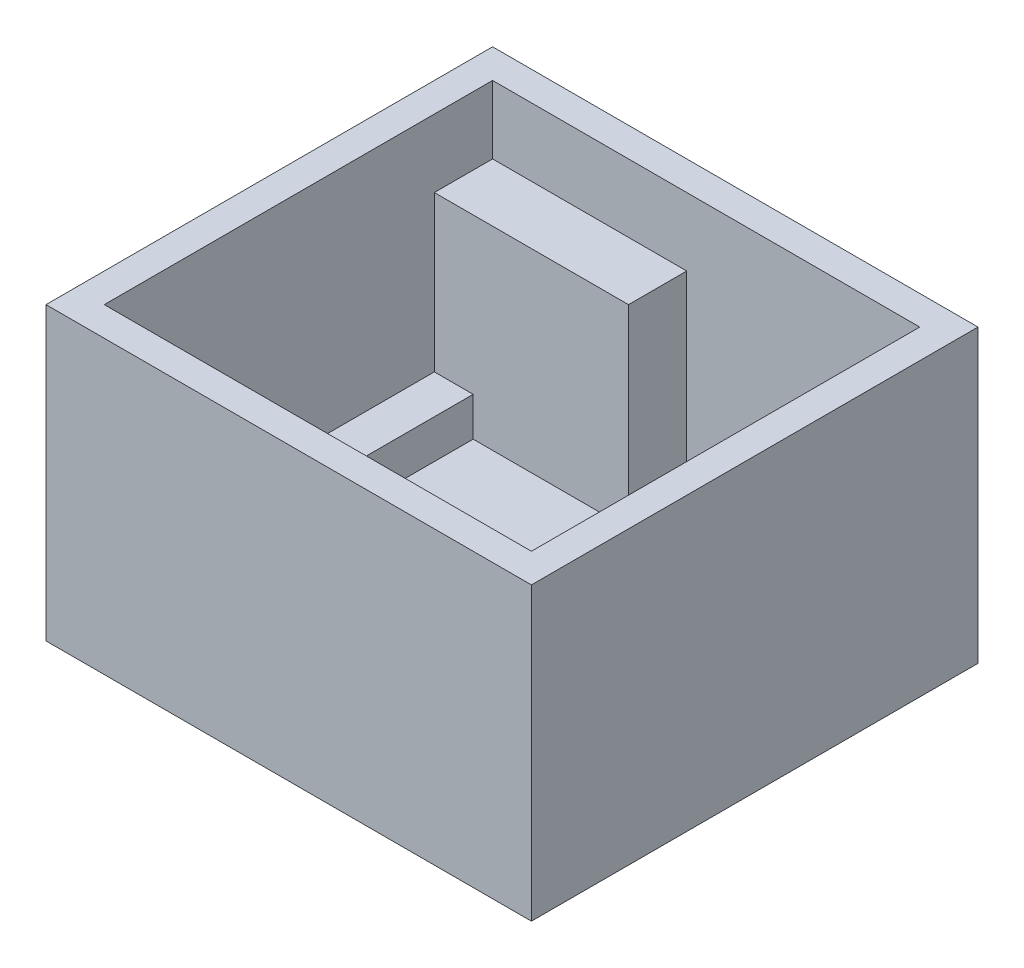
from build123d import *

# Parameters (mm, degrees)
SKETCH1_W           = 25
SKETCH1_H           = 23
BOSS_EXTRUDE1_DEPTH = 15
SHELL1_T            = -1.5
SKETCH3_W           = 2
SKETCH3_H           = 2
BOSS_EXTRUDE2_DEPTH = 2
SKETCH4_W           = 2
SKETCH4_H           = 7
BOSS_EXTRUDE3_DEPTH = 2
SKETCH5_W           = 10
SKETCH5_H           = 3
BOSS_EXTRUDE4_DEPTH = 10
SKETCH2_R           = 1.75
BOSS_EXTRUDE5_DEPTH = 2
SKETCH6_R           = 1.25
BOSS_EXTRUDE6_DEPTH = 4


with BuildPart() as part:
    # Sketch1 → Boss-Extrude1 (new body)
    with BuildSketch(Plane(origin=(0, 0, 0), x_dir=(1, 0, 0), z_dir=(0, 1, 0))):
        Rectangle(SKETCH1_W, SKETCH1_H)
    extrude(amount=BOSS_EXTRUDE1_DEPTH)

    # Shell1
    shell1_openings = [part.faces().sort_by_distance(p)[0] for p in [
        (0, 15, 0),
    ]]
    offset(amount=SHELL1_T, openings=shell1_openings, kind=Kind.INTERSECTION)

    # Sketch3 → Boss-Extrude2 (add)
    with BuildSketch(Plane(origin=(0, 1.5, 0), x_dir=(1, 0, 0), z_dir=(0, 1, 0))):
        with Locations((-10, 9)):
            Rectangle(SKETCH3_W, SKETCH3_H)
        with Locations((10, 9)):
            Rectangle(SKETCH3_W, SKETCH3_H)
        with Locations((10, -9)):
            Rectangle(SKETCH3_W, SKETCH3_H)
        with Locations((-10, -9)):
            Rectangle(SKETCH3_W, SKETCH3_H)
    extrude(amount=BOSS_EXTRUDE2_DEPTH)

    # Sketch4 → Boss-Extrude3 (add)
    with BuildSketch(Plane(origin=(0, 1.5, 0), x_dir=(1, 0, 0), z_dir=(0, 1, 0))):
        with Locations((-10, 4.5)):
            Rectangle(SKETCH4_W, SKETCH4_H)
        with Locations((10, 4.5)):
            Rectangle(SKETCH4_W, SKETCH4_H)
    extrude(amount=BOSS_EXTRUDE3_DEPTH)

    # Sketch5 → Boss-Extrude4 (add)
    with BuildSketch(Plane(origin=(0, 1.5, 0), x_dir=(1, 0, 0), z_dir=(0, 1, 0))):
        with Locations((-6, 8.5)):
            Rectangle(SKETCH5_W, SKETCH5_H)
    extrude(amount=BOSS_EXTRUDE4_DEPTH)

    # Sketch2 → Boss-Extrude5 (add)
    with BuildSketch(Plane(origin=(0, 1.5, 0), x_dir=(1, 0, 0), z_dir=(0, 1, 0))):
        with Locations((-8.2, -7.25)):
            Circle(SKETCH2_R)
        with Locations((8.2, -7.25)):
            Circle(SKETCH2_R)
    extrude(amount=BOSS_EXTRUDE5_DEPTH)

    # Sketch6 → Boss-Extrude6 (add)
    with BuildSketch(Plane(origin=(0, 3.5, 0), x_dir=(1, 0, 0), z_dir=(0, 1, 0))):
        with Locations((-8.2, -7.25)):
            Circle(SKETCH6_R)
        with Locations((8.2, -7.25)):
            Circle(SKETCH6_R)
    extrude(amount=BOSS_EXTRUDE6_DEPTH)


solid = part.part
